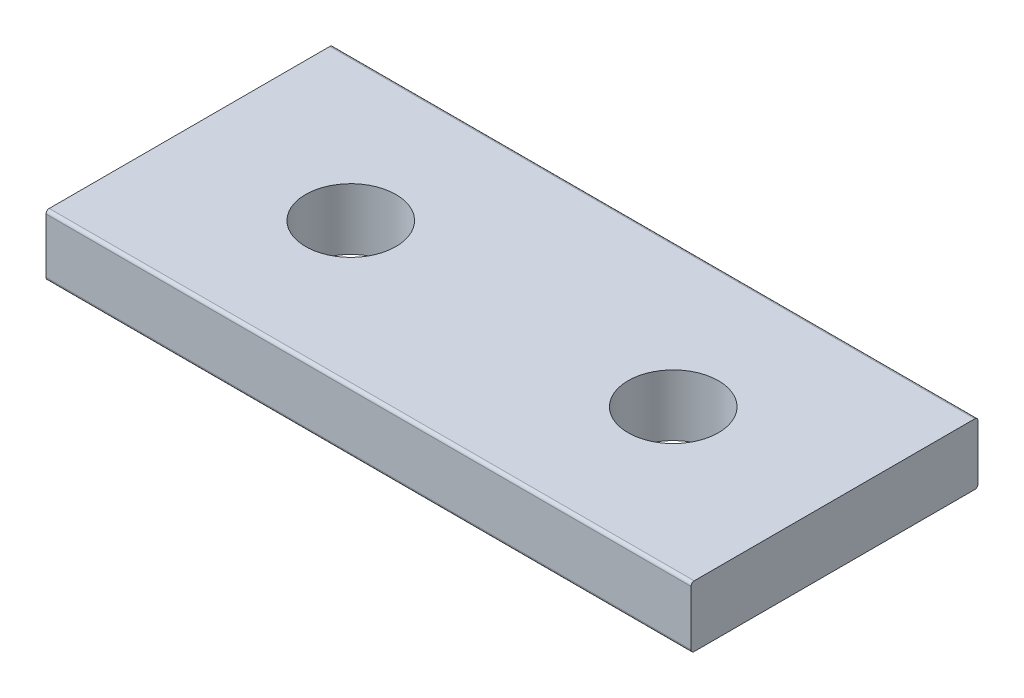
from build123d import *

# Parameters (mm, degrees)
SKETCH1_W                      = 40
SKETCH1_H                      = 17.8
BOSS_EXTRUDE1_DEPTH            = 3.8
F_5_6_5_6_DIAMETER_HOLE1_D     = 5.6
F_5_6_5_6_DIAMETER_HOLE1_DEPTH = 3.8
FILLET1_R                      = 0.2


with BuildPart() as part:
    # Sketch1 → Boss-Extrude1 (new body)
    with BuildSketch(Plane(origin=(0, 1.9, 0), x_dir=(1, 0, 0), z_dir=(0, 1, 0))):
        Rectangle(SKETCH1_W, SKETCH1_H)
    extrude(amount=-BOSS_EXTRUDE1_DEPTH)

    # Ø5.6 (5.6) Diameter Hole1
    with Locations(Plane(origin=(0, -1.9, 0), x_dir=(-1, 0, 0), z_dir=(0, -1, 0))):
        with Locations((10, 0), (-10, 0)):
            Hole(F_5_6_5_6_DIAMETER_HOLE1_D / 2, depth=F_5_6_5_6_DIAMETER_HOLE1_DEPTH)

    # Fillet1
    fillet1_edges = [part.edges().sort_by_distance(p)[0] for p in [
        (0, -1.9, -8.9),
        (0, -1.9, 8.9),
        (0, 1.9, -8.9),
        (0, 1.9, 8.9),
    ]]
    fillet(fillet1_edges, radius=FILLET1_R)


solid = part.part
